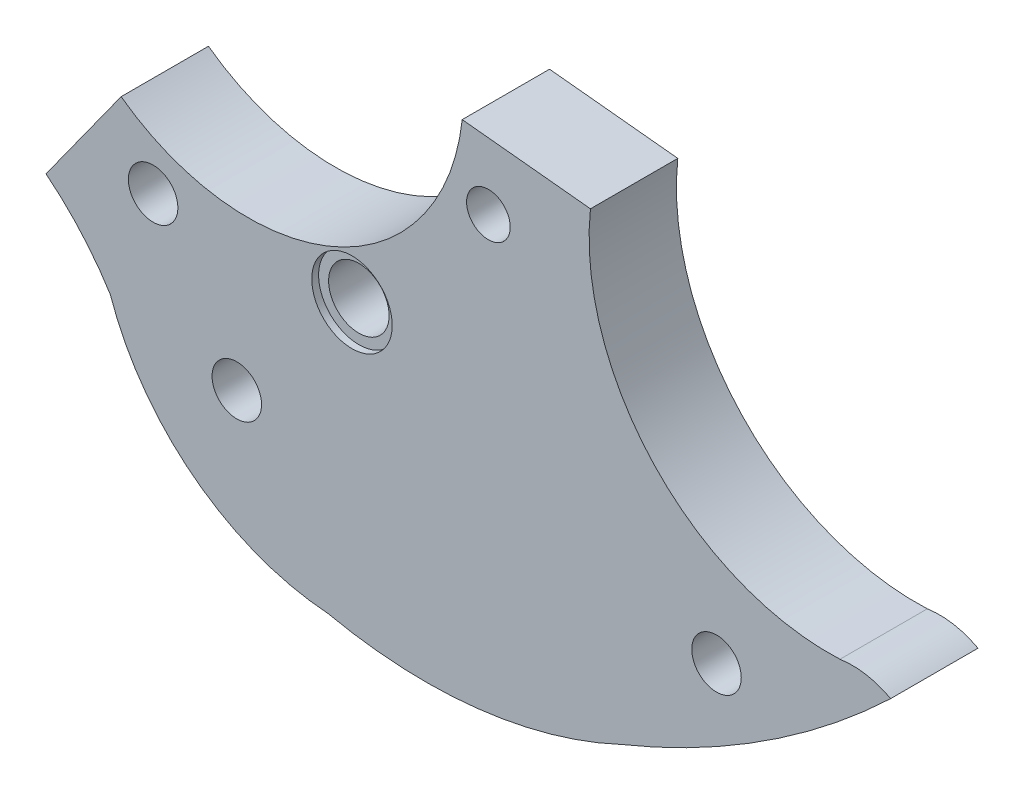
from build123d import *

# Parameters (mm, degrees)
ESBO_O1_R                = 3.175
ESBO_O1_R_2              = 3.6
ESBO_O1_R_3              = 4.4
RESSALTO_EXTRUS_O1_DEPTH = 12.7
ESBO_O3_R                = 5.85
CORTE_EXTRUS_O1_DEPTH    = 1


with BuildPart() as part:
    # Esboço1 → Ressalto-extrusão1 (new body)
    with BuildSketch(Plane.XY):
        with BuildLine():
            Line((68.264029726, 80.471482556), (86.913718709, 78.564915838))
            ThreePointArc((86.913718709, 78.564915838), (96.190192778, 50.934582064), (123.199407881, 39.98055928))
            ThreePointArc((123.199407881, 39.98055928), (126.9879217, 39.943074462), (130.568554452, 38.704805036))
            ThreePointArc((130.568554452, 38.704805036), (112.191596118, 24.182863465), (91.421685961, 13.356496733))
            ThreePointArc((91.421685961, 13.356496733), (70.502377652, 7.424980082), (48.785297914, 8.506089469))
            ThreePointArc((48.785297914, 8.506089469), (29.282001901, 15.926871282), (17.091631159, 32.863264618))
            ThreePointArc((17.091631159, 32.863264618), (12.862793068, 38.519278229), (7.740980224, 43.381437705))
            Line((7.740980224, 43.381437705), (18.663600862, 58.560101484))
            ThreePointArc((18.663600862, 58.560101484), (49.782513053, 55.212261005), (68.264029726, 80.471482556))
        make_face()
        with Locations((72.07343938, 70.420125946)):
            Circle(ESBO_O1_R, mode=Mode.SUBTRACT)
        with Locations((23.31829005, 48.678964138)):
            Circle(ESBO_O1_R_2, mode=Mode.SUBTRACT)
        with Locations((35.486495683, 29.988548249)):
            Circle(ESBO_O1_R_2, mode=Mode.SUBTRACT)
        with Locations((105.243732184, 30.464144141)):
            Circle(ESBO_O1_R_2, mode=Mode.SUBTRACT)
        with Locations((52.234302046, 49.457669457)):
            Circle(ESBO_O1_R_3, mode=Mode.SUBTRACT)
    extrude(amount=RESSALTO_EXTRUS_O1_DEPTH)

    # Esboço3 → Corte-extrusão1 (cut)
    with BuildSketch(Plane.XY.offset(12.7)):
        with Locations((52.234302046, 49.457669457)):
            Circle(ESBO_O3_R)
    extrude(amount=-CORTE_EXTRUS_O1_DEPTH, mode=Mode.SUBTRACT)


solid = part.part
